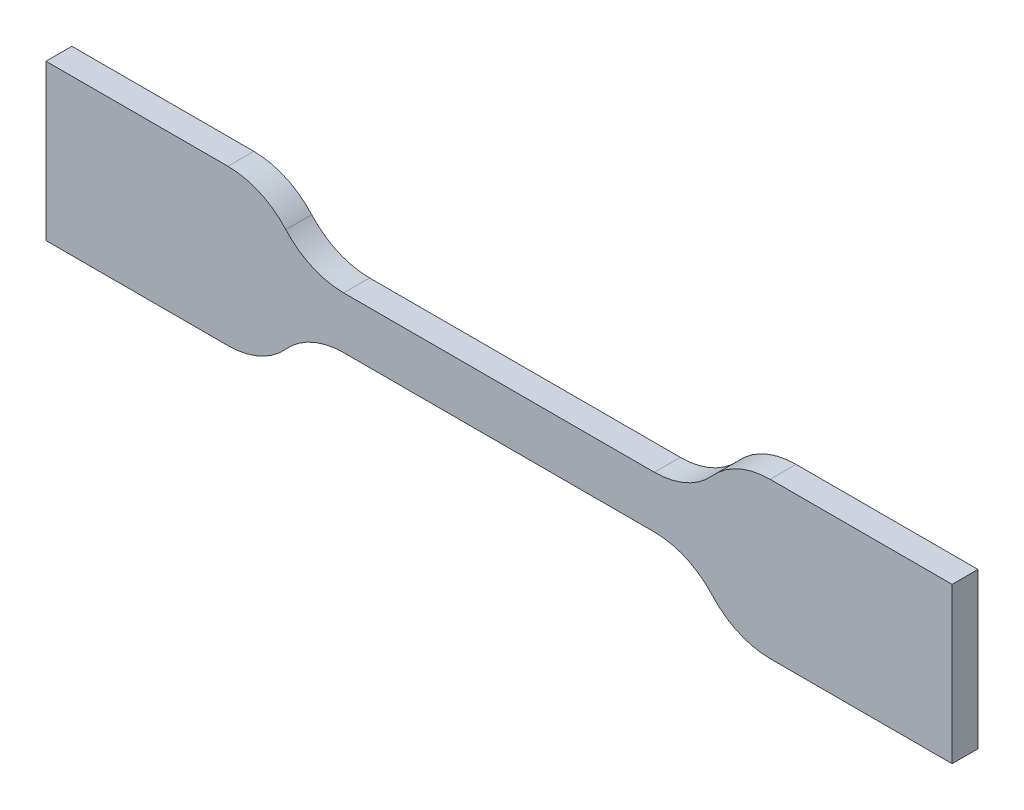
from build123d import *

# Parameters (mm, degrees)
BOSS_EXTRUDE1_DEPTH = 0.5


with BuildPart() as part:
    # Sketch1 → Boss-Extrude1 (new body, symmetric)
    with BuildSketch(Plane.XY):
        with BuildLine():
            Line((-17.5, 3), (-17.5, -3))
            Line((-17.5, -3), (-10.472135955, -3))
            ThreePointArc((-10.472135955, -3), (-9.247391084, -2.738612788), (-8.236067977, -2))
            ThreePointArc((-8.236067977, -2), (-7.224744871, -1.261387212), (-6, -1))
            Line((-6, -1), (6, -1))
            ThreePointArc((6, -1), (7.224744871, -1.261387212), (8.236067977, -2))
            ThreePointArc((8.236067977, -2), (9.247391084, -2.738612788), (10.472135955, -3))
            Line((10.472135955, -3), (17.5, -3))
            Line((17.5, -3), (17.5, 3))
            Line((17.5, 3), (10.472135955, 3))
            ThreePointArc((10.472135955, 3), (9.247391084, 2.738612788), (8.236067977, 2))
            ThreePointArc((8.236067977, 2), (7.224744871, 1.261387212), (6, 1))
            Line((6, 1), (-6, 1))
            ThreePointArc((-6, 1), (-7.224744871, 1.261387212), (-8.236067977, 2))
            ThreePointArc((-8.236067977, 2), (-9.247391084, 2.738612788), (-10.472135955, 3))
            Line((-10.472135955, 3), (-17.5, 3))
        make_face()
    extrude(amount=BOSS_EXTRUDE1_DEPTH, both=True)


solid = part.part
